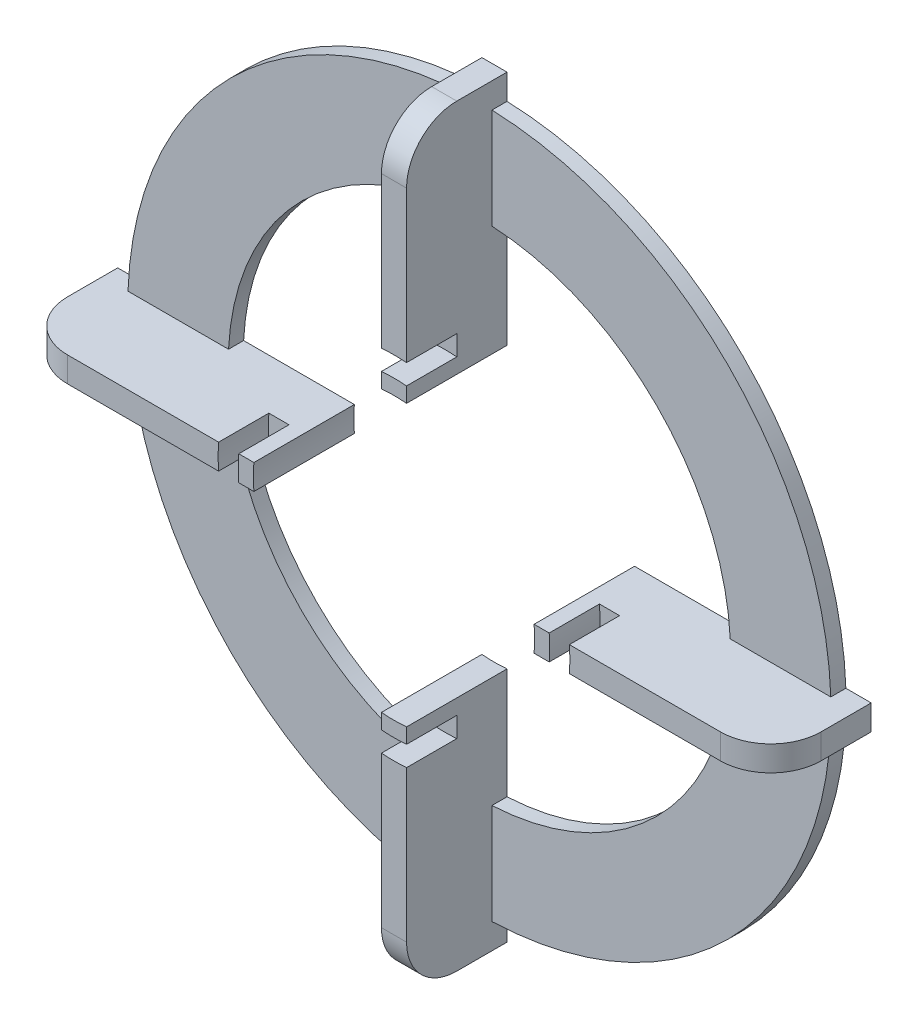
from build123d import *

# Parameters (mm, degrees)
SKETCH1_W           = 72.5
SKETCH1_H           = 5
SKETCH1_W_2         = 5
SKETCH1_H_2         = 72.5
BOSS_EXTRUDE1_DEPTH = 20
SKETCH2_R           = 70
SKETCH2_R_2         = 50
BOSS_EXTRUDE2_DEPTH = 3
SKETCH3_R           = 35
SKETCH3_R_2         = 31
CUT_EXTRUDE1_DEPTH  = 10
SKETCH4_R           = 28
CUT_EXTRUDE2_DEPTH  = 21
FILLET1_R           = 10
FILLET2_R           = 10
FILLET3_R           = 10
FILLET4_R           = 10


with BuildPart() as part:
    # Sketch1 → Boss-Extrude1 (new body)
    with BuildSketch(Plane.XY):
        with Locations((-38.75, 0)):
            Rectangle(SKETCH1_W, SKETCH1_H)
        with Locations((38.75, 0)):
            Rectangle(SKETCH1_W, SKETCH1_H)
        with Locations((0, 38.75)):
            Rectangle(SKETCH1_W_2, SKETCH1_H_2)
        with Locations((0, -38.75)):
            Rectangle(SKETCH1_W_2, SKETCH1_H_2)
        Rectangle(SKETCH1_W_2, SKETCH1_H)
    extrude(amount=BOSS_EXTRUDE1_DEPTH)

    # Sketch2 → Boss-Extrude2 (add)
    with BuildSketch(Plane(origin=(0, 0, 0), x_dir=(-1, 0, 0), z_dir=(0, 0, -1))):
        Circle(SKETCH2_R)
        Circle(SKETCH2_R_2, mode=Mode.SUBTRACT)
    extrude(amount=-BOSS_EXTRUDE2_DEPTH)

    # Sketch3 → Cut-Extrude1 (cut)
    with BuildSketch(Plane.XY.offset(20)):
        Circle(SKETCH3_R)
        Circle(SKETCH3_R_2, mode=Mode.SUBTRACT)
    extrude(amount=-CUT_EXTRUDE1_DEPTH, mode=Mode.SUBTRACT)

    # Sketch4 → Cut-Extrude2 (cut, through all)
    with BuildSketch(Plane.XY.offset(20)):
        Circle(SKETCH4_R)
    extrude(amount=-CUT_EXTRUDE2_DEPTH, mode=Mode.SUBTRACT)

    # Fillet1
    fillet1_edges = [part.edges().sort_by_distance(p)[0] for p in [
        (0, 75, 20),
    ]]
    fillet(fillet1_edges, radius=FILLET1_R)

    # Fillet2
    fillet2_edges = [part.edges().sort_by_distance(p)[0] for p in [
        (75, 0, 20),
    ]]
    fillet(fillet2_edges, radius=FILLET2_R)

    # Fillet3
    fillet3_edges = [part.edges().sort_by_distance(p)[0] for p in [
        (-75, 0, 20),
    ]]
    fillet(fillet3_edges, radius=FILLET3_R)

    # Fillet4
    fillet4_edges = [part.edges().sort_by_distance(p)[0] for p in [
        (0, -75, 20),
    ]]
    fillet(fillet4_edges, radius=FILLET4_R)


solid = part.part
